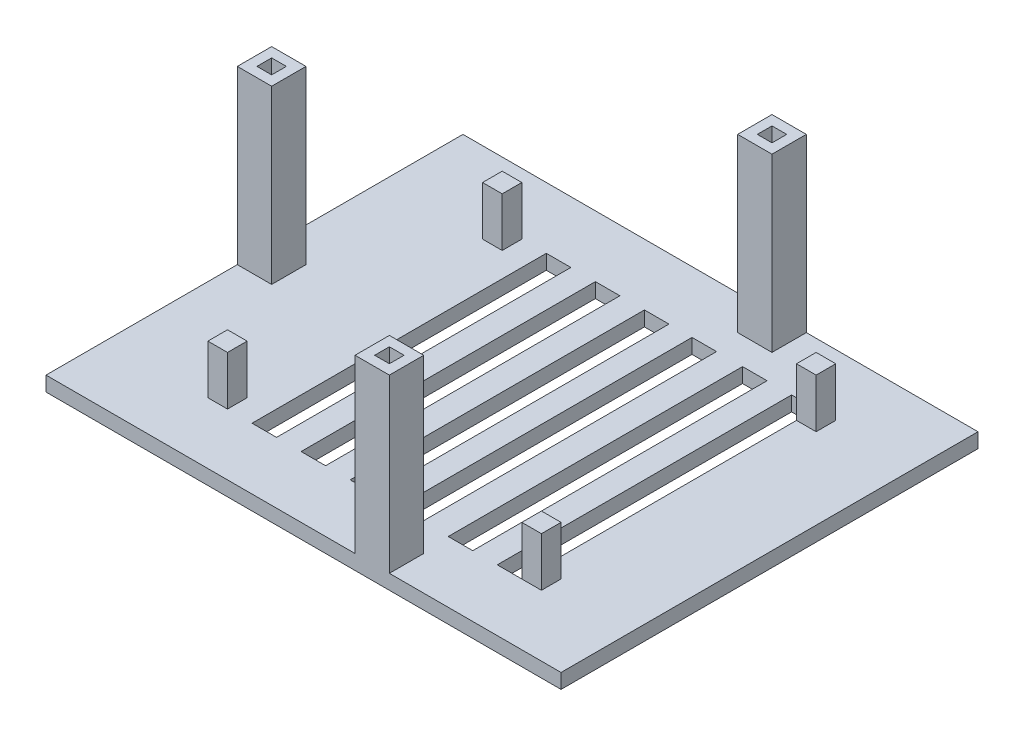
from build123d import *

# Parameters (mm, degrees)
SKETCH3_W           = 105
SKETCH3_H           = 85
BOSS_EXTRUDE3_DEPTH = 3
SKETCH5_W           = 7
SKETCH5_H           = 7
SKETCH5_W_2         = 3
SKETCH5_H_2         = 3
BOSS_EXTRUDE4_DEPTH = 35
SKETCH9_W           = 2.998895248
SKETCH9_H           = 2.995380601
BOSS_EXTRUDE5_DEPTH = 35
SKETCH11_W          = 7
SKETCH11_H          = 7
SKETCH11_W_2        = 3
SKETCH11_H_2        = 3
BOSS_EXTRUDE6_DEPTH = 35
CUT_EXTRUDE1_DEPTH  = 6
SKETCH14_W          = 5
SKETCH14_H          = 60
CUT_EXTRUDE3_DEPTH  = 33
SKETCH17_W          = 5
SKETCH17_H          = 60
CUT_EXTRUDE4_DEPTH  = 15
SKETCH18_W          = 4
SKETCH18_H          = 4
BOSS_EXTRUDE7_DEPTH = 10


with BuildPart() as part:
    # Sketch3 → Boss-Extrude3 (new body)
    with BuildSketch(Plane(origin=(0, 0, 0), x_dir=(1, 0, 0), z_dir=(0, 1, 0))):
        with Locations((-2.316884661, -22.898810939)):
            Rectangle(SKETCH3_W, SKETCH3_H)
    extrude(amount=BOSS_EXTRUDE3_DEPTH)

    # Sketch5 → Boss-Extrude4 (add)
    with BuildSketch(Plane(origin=(0, 3, 0), x_dir=(1, 0, 0), z_dir=(0, 1, 0))):
        with Locations((11.683115339, -61.898810939)):
            Rectangle(SKETCH5_W, SKETCH5_H)
        with Locations((11.683115339, -61.898810939)):
            Rectangle(SKETCH5_W_2, SKETCH5_H_2, mode=Mode.SUBTRACT)
    extrude(amount=BOSS_EXTRUDE4_DEPTH)

    # Sketch9 → Boss-Extrude5 (add)
    with BuildSketch(Plane(origin=(0, 3, 0), x_dir=(1, 0, 0), z_dir=(0, 1, 0))):
        Polygon((15.183115339, 12.601189061), (15.183115339, 19.601189061), (8.183115339, 19.601189061), (8.183115339, 17.600348451), (8.183115339, 12.601189061), align=None)
        with Locations((11.687877227, 16.102658151)):
            Rectangle(SKETCH9_W, SKETCH9_H, mode=Mode.SUBTRACT)
    extrude(amount=BOSS_EXTRUDE5_DEPTH)

    # Sketch11 → Boss-Extrude6 (add)
    with BuildSketch(Plane(origin=(0, 3, 0), x_dir=(1, 0, 0), z_dir=(0, 1, 0))):
        with Locations((-51.316884661, -22.898810939)):
            Rectangle(SKETCH11_W, SKETCH11_H)
        with Locations((-51.316884661, -22.898810939)):
            Rectangle(SKETCH11_W_2, SKETCH11_H_2, mode=Mode.SUBTRACT)
    extrude(amount=BOSS_EXTRUDE6_DEPTH)

    # Sketch12 → Cut-Extrude1 (cut)
    with BuildSketch(Plane(origin=(0, 3, 0), x_dir=(1, 0, 0), z_dir=(0, 1, 0))):
        Polygon((29.683115339, -52.898810939), (29.683115339, -48.898810939), (29.683115339, 3.101189061), (29.683115339, 7.101189061), (24.683115339, 7.101189061), (24.683115339, -52.898810939), align=None)
    extrude(amount=-CUT_EXTRUDE1_DEPTH, mode=Mode.SUBTRACT)

    # Sketch14 → Cut-Extrude3 (cut)
    with BuildSketch(Plane(origin=(0, 3, 0), x_dir=(1, 0, 0), z_dir=(0, 1, 0))):
        with Locations((17.183115339, -22.898810939)):
            Rectangle(SKETCH14_W, SKETCH14_H)
        with Locations((-2.816884661, -22.898810939)):
            Rectangle(SKETCH14_W, SKETCH14_H)
        with Locations((-22.816884661, -22.898810939)):
            Rectangle(SKETCH14_W, SKETCH14_H)
        with Locations((-12.816884661, -22.898810939)):
            Rectangle(SKETCH14_W, SKETCH14_H)
    extrude(amount=-CUT_EXTRUDE3_DEPTH, mode=Mode.SUBTRACT)

    # Sketch17 → Cut-Extrude4 (cut)
    with BuildSketch(Plane(origin=(0, 3, 0), x_dir=(1, 0, 0), z_dir=(0, 1, 0))):
        with Locations((6.882849783, -22.898810939)):
            Rectangle(SKETCH17_W, SKETCH17_H)
    extrude(amount=-CUT_EXTRUDE4_DEPTH, mode=Mode.SUBTRACT)

    # Sketch18 → Boss-Extrude7 (add)
    with BuildSketch(Plane(origin=(0, 3, 0), x_dir=(1, 0, 0), z_dir=(0, 1, 0))):
        with Locations((31.683115339, -50.898810939)):
            Rectangle(SKETCH18_W, SKETCH18_H)
        with Locations((31.683115339, 5.101189061)):
            Rectangle(SKETCH18_W, SKETCH18_H)
        with Locations((-32.316884661, 5.101189061)):
            Rectangle(SKETCH18_W, SKETCH18_H)
        with Locations((-32.316884661, -50.898810939)):
            Rectangle(SKETCH18_W, SKETCH18_H)
    extrude(amount=BOSS_EXTRUDE7_DEPTH)


solid = part.part
